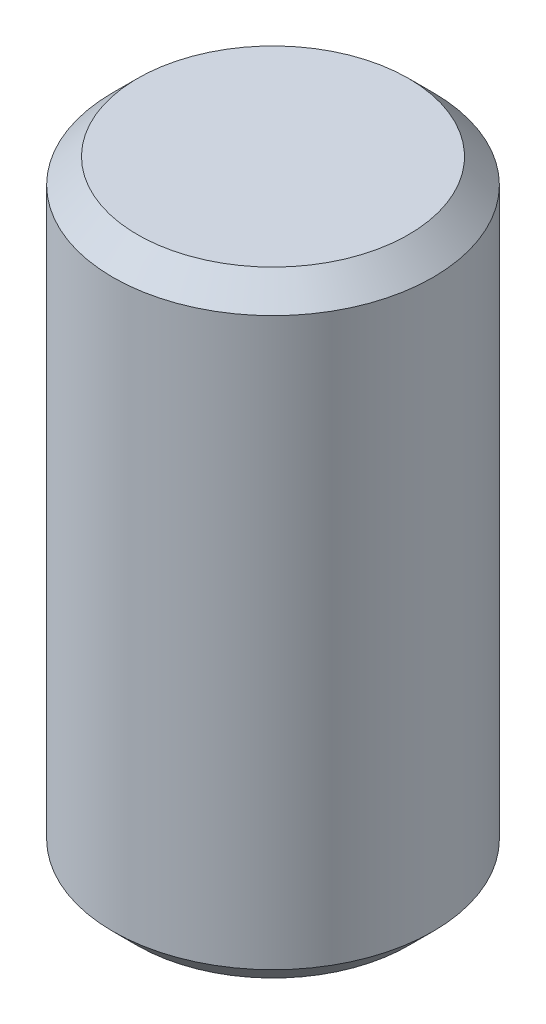
from build123d import *

# Parameters (mm, degrees)
SKETCH1_W     = 3.302
SKETCH1_H     = 12.7
CHAMFER1_SIZE = 0.508


with BuildPart() as part:
    # Sketch1 → Revolve1 (revolve)
    with BuildSketch(Plane.XY):
        with Locations((1.651, 0)):
            Rectangle(SKETCH1_W, SKETCH1_H)
    revolve(axis=Axis((0, 6.080207887, 0), (0, -1, 0)))

    # Chamfer1
    chamfer1_edges = [part.edges().sort_by_distance(p)[0] for p in [
        (-3.302, 6.35, 0),
        (-3.302, -6.35, 0),
    ]]
    chamfer(chamfer1_edges, length=CHAMFER1_SIZE)


solid = part.part
